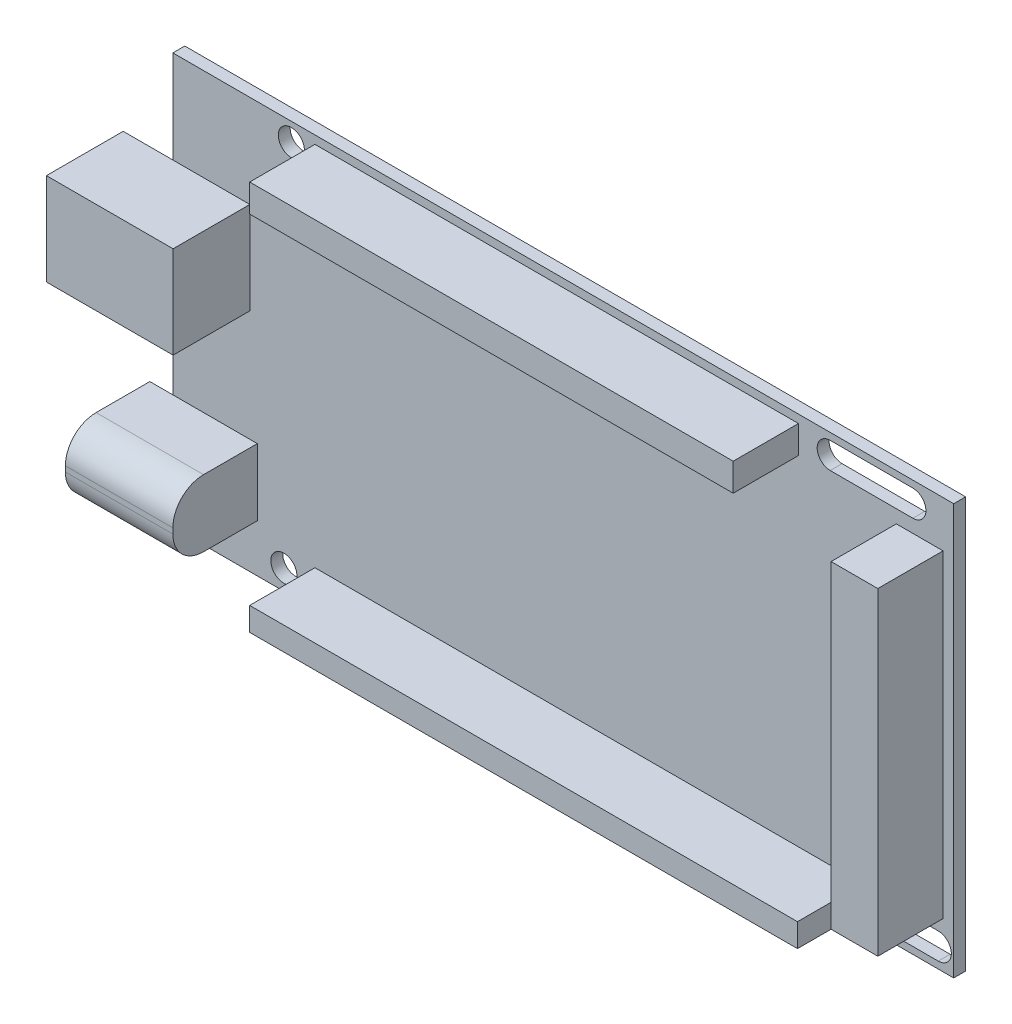
from build123d import *

# Parameters (mm, degrees)
SKETCH_1_W          = 101.7
SKETCH_1_H          = 53.5
EXTRUDE_1_DEPTH     = 1.55
SKETCH_2_R          = 1.7
CUT_EXTRUDE_1_DEPTH = 1.55
SKETCH_3_W          = 16.5
SKETCH_3_H          = 12
EXTRUDE_2_DEPTH     = 10
SKETCH_4_W          = 14
SKETCH_4_H          = 8.7
EXTRUDE_3_DEPTH     = 11
FILLET_1_R          = 4
SKETCH_5_W          = 8.402583841
SKETCH_5_H          = 9.620349616
CUT_EXTRUDE_3_DEPTH = 12.6
SKETCH_6_R          = 3.3
CUT_EXTRUDE_4_DEPTH = 12.6
SKETCH_7_W          = 62.975416122
SKETCH_7_H          = 3.61490304
SKETCH_7_W_2        = 6.088257752
SKETCH_7_H_2        = 41.476255936
SKETCH_7_W_3        = 71.346770532
SKETCH_7_H_3        = 3.044128877
EXTRUDE_4_DEPTH     = 8.5


with BuildPart() as part:
    # 草图1 → 凸台-拉伸1 (new body)
    with BuildSketch(Plane.XY):
        with Locations((1.649757161, 1.28884807)):
            Rectangle(SKETCH_1_W, SKETCH_1_H)
    extrude(amount=EXTRUDE_1_DEPTH)

    # 草图2 → 切除-拉伸1 (cut)
    with BuildSketch(Plane.XY.offset(1.55)):
        with Locations((-34.740242839, -22.86115193)):
            Circle(SKETCH_2_R)
        with Locations((-33.770242839, 25.63884807)):
            Circle(SKETCH_2_R)
        with BuildLine():
            Line((36.418676462, 27.13884807), (47.180837859, 27.13884807))
            ThreePointArc((47.180837859, 27.13884807), (48.880837859, 25.43884807), (47.180837859, 23.73884807))
            Line((47.180837859, 23.73884807), (36.418676462, 23.73884807))
            ThreePointArc((36.418676462, 23.73884807), (34.718676462, 25.43884807), (36.418676462, 27.13884807))
        make_face()
        with BuildLine():
            Line((45.109216811, -21.16115193), (50.49029751, -21.16115193))
            ThreePointArc((50.49029751, -21.16115193), (52.19029751, -22.86115193), (50.49029751, -24.56115193))
            Line((50.49029751, -24.56115193), (45.109216811, -24.56115193))
            ThreePointArc((45.109216811, -24.56115193), (43.409216811, -22.86115193), (45.109216811, -21.16115193))
        make_face()
    extrude(amount=-CUT_EXTRUDE_1_DEPTH, mode=Mode.SUBTRACT)

    # 草图3 → 凸台-拉伸2 (add)
    with BuildSketch(Plane.XY.offset(1.55)):
        with Locations((-47.420242839, 9.956852339)):
            Rectangle(SKETCH_3_W, SKETCH_3_H)
    extrude(amount=EXTRUDE_2_DEPTH)

    # 草图4 → 凸台-拉伸3 (add)
    with BuildSketch(Plane.XY.offset(1.55)):
        with Locations((-45.200242839, -14.884453356)):
            Rectangle(SKETCH_4_W, SKETCH_4_H)
    extrude(amount=EXTRUDE_3_DEPTH)

    # 圆角1
    fillet_1_edges = [part.edges().sort_by_distance(p)[0] for p in [
        (-45.200242839, -10.534453356, 12.55),
        (-45.200242839, -19.234453356, 12.55),
    ]]
    fillet(fillet_1_edges, radius=FILLET_1_R)

    # 草图5 → 切除-拉伸3 (cut)
    with BuildSketch(Plane.ZY.offset(55.670242839)):
        with Locations((6.770558557, 9.995873355)):
            Rectangle(SKETCH_5_W, SKETCH_5_H)
    extrude(amount=-CUT_EXTRUDE_3_DEPTH, mode=Mode.SUBTRACT)

    # 草图6 → 切除-拉伸4 (cut)
    with BuildSketch(Plane.ZY.offset(52.200242839)):
        with Locations((8.55, -14.534453356)):
            Circle(SKETCH_6_R)
    extrude(amount=-CUT_EXTRUDE_4_DEPTH, mode=Mode.SUBTRACT)

    # 草图7 → 凸台-拉伸4 (add)
    with BuildSketch(Plane.XY.offset(1.55)):
        with Locations((0.792982845, 25.166233941)):
            Rectangle(SKETCH_7_W, SKETCH_7_H)
        with Locations((48.072109451, 1.28884807)):
            Rectangle(SKETCH_7_W_2, SKETCH_7_H_2)
        with Locations((4.97866005, -22.30315072)):
            Rectangle(SKETCH_7_W_3, SKETCH_7_H_3)
    extrude(amount=EXTRUDE_4_DEPTH)


solid = part.part
